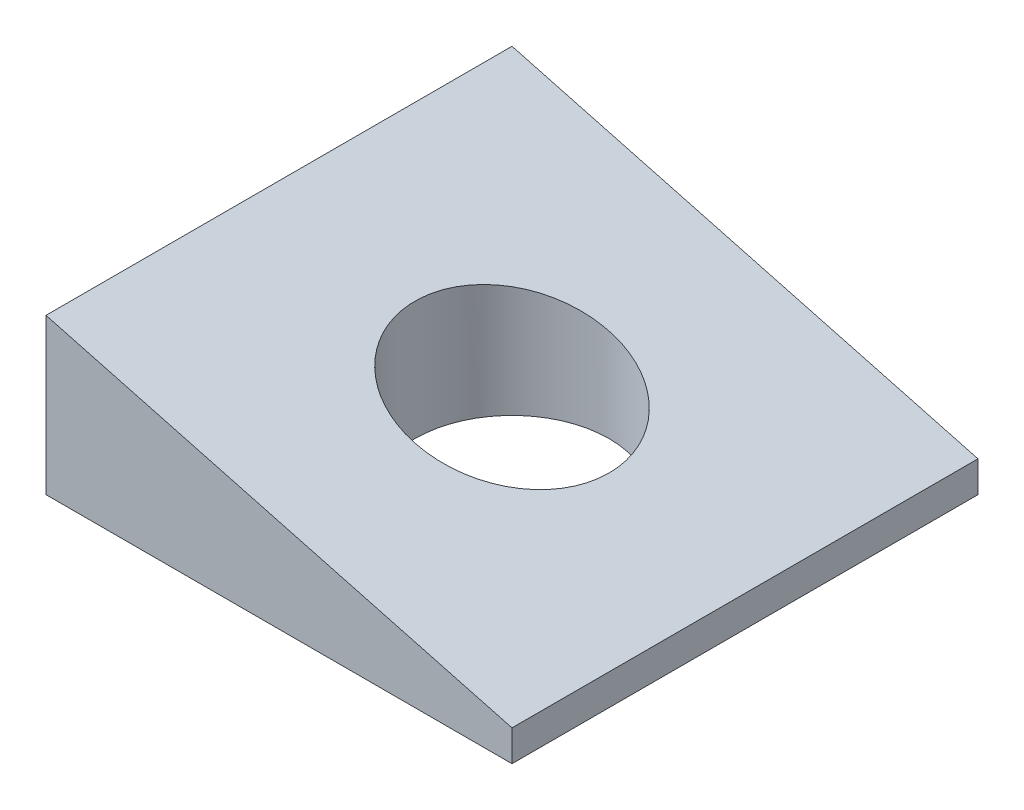
from build123d import *

# Parameters (mm, degrees)
BOSS_EXTRUDE1_DEPTH = 38.1
SKETCH2_R           = 7.9375
CUT_EXTRUDE1_DEPTH  = 38.1


with BuildPart() as part:
    # Sketch1 → Boss-Extrude1 (new body)
    with BuildSketch(Plane.XY):
        Polygon((0, 0), (0, 12.7), (38.1, 2.54), (38.1, 0), align=None)
    extrude(amount=BOSS_EXTRUDE1_DEPTH)

    # Sketch2 → Cut-Extrude1 (cut)
    with BuildSketch(Plane.XZ):
        with Locations((19.05, 19.05)):
            Circle(SKETCH2_R)
    extrude(amount=-CUT_EXTRUDE1_DEPTH, mode=Mode.SUBTRACT)


solid = part.part
